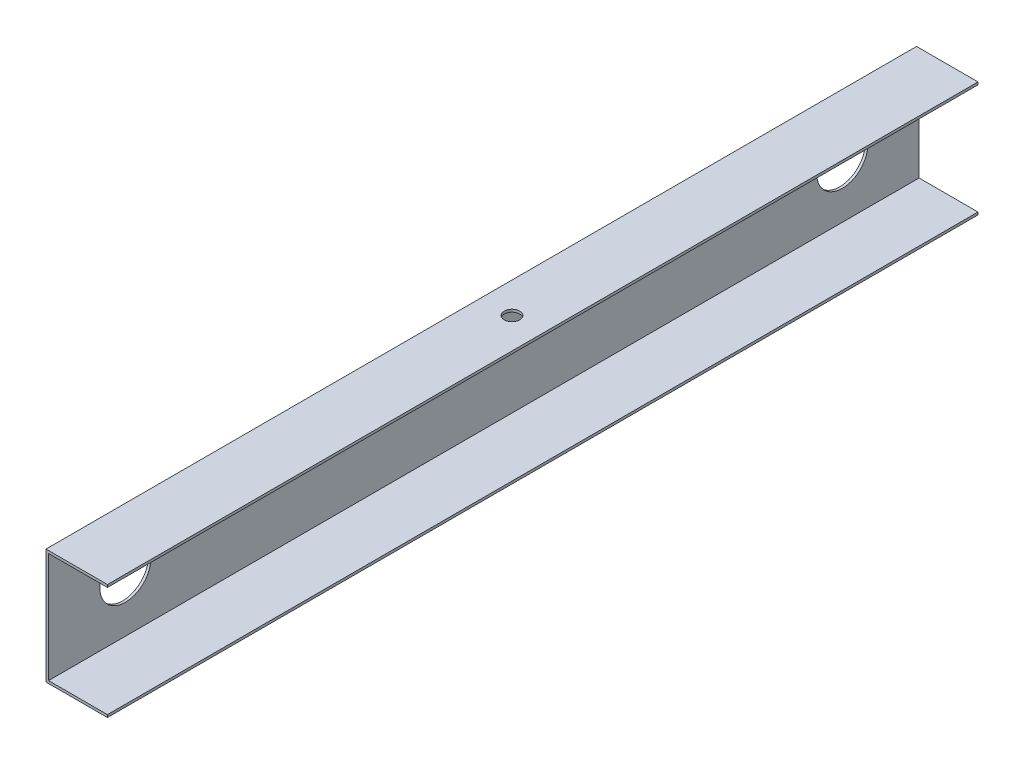
from build123d import *

# Parameters (mm, degrees)
BOSS_EXTRUDE1_DEPTH = 340
SKETCH3_R           = 10
CUT_EXTRUDE1_DEPTH  = 340
SKETCH4_R           = 3
CUT_EXTRUDE2_DEPTH  = 25


with BuildPart() as part:
    # Sketch2 → Boss-Extrude1 (new body)
    with BuildSketch(Plane.XY):
        Polygon((0, 0), (24, 0), (24, -1), (1, -1), (1, -44), (24, -44), (24, -45), (0, -45), align=None)
    extrude(amount=BOSS_EXTRUDE1_DEPTH)

    # Sketch3 → Cut-Extrude1 (cut)
    with BuildSketch(Plane.ZY):
        with Locations((30, -22.5)):
            Circle(SKETCH3_R)
        with Locations((310, -22.5)):
            Circle(SKETCH3_R)
    extrude(amount=-CUT_EXTRUDE1_DEPTH, mode=Mode.SUBTRACT)

    # Sketch4 → Cut-Extrude2 (cut)
    with BuildSketch(Plane(origin=(0, 0, 0), x_dir=(1, 0, 0), z_dir=(0, 1, 0))):
        with Locations((12, -170)):
            Circle(SKETCH4_R)
    extrude(amount=-CUT_EXTRUDE2_DEPTH, mode=Mode.SUBTRACT)


solid = part.part
